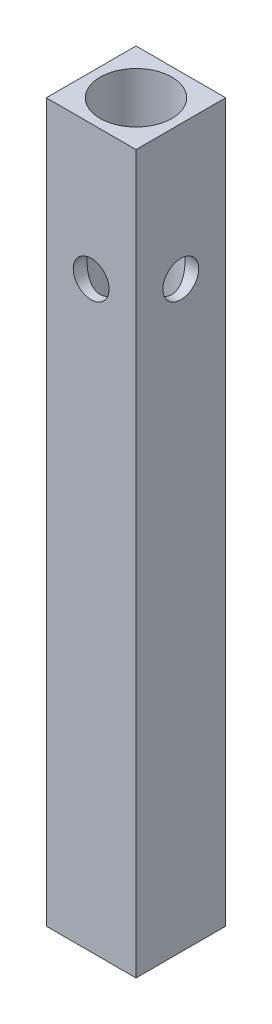
from build123d import *

# Parameters (mm, degrees)
SKETCH_1_W          = 10
SKETCH_1_H          = 10
EXTRUDE_1_DEPTH     = 80
SKETCH_4_R          = 4
CUT_EXTRUDE_3_DEPTH = 75
SKETCH_5_R          = 2
CUT_EXTRUDE_4_DEPTH = 11
SKETCH_6_R          = 2
CUT_EXTRUDE_5_DEPTH = 10


with BuildPart() as part:
    # 草图1 → 凸台-拉伸1 (new body)
    with BuildSketch(Plane(origin=(0, 0, 0), x_dir=(1, 0, 0), z_dir=(0, 1, 0))):
        Rectangle(SKETCH_1_W, SKETCH_1_H)
    extrude(amount=EXTRUDE_1_DEPTH)

    # 草图4 → 切除-拉伸3 (cut)
    with BuildSketch(Plane(origin=(0, 80, 0), x_dir=(1, 0, 0), z_dir=(0, 1, 0))):
        Circle(SKETCH_4_R)
    extrude(amount=-CUT_EXTRUDE_3_DEPTH, mode=Mode.SUBTRACT)

    # 草图5 → 切除-拉伸4 (cut, through all)
    with BuildSketch(Plane(origin=(5, 0, 0), x_dir=(0, 0, -1), z_dir=(1, 0, 0))):
        with Locations((0, 65)):
            Circle(SKETCH_5_R)
    extrude(amount=-CUT_EXTRUDE_4_DEPTH, mode=Mode.SUBTRACT)

    # 草图6 → 切除-拉伸5 (cut)
    with BuildSketch(Plane(origin=(0, 0, -5), x_dir=(-1, 0, 0), z_dir=(0, 0, -1))):
        with Locations((0, 65)):
            Circle(SKETCH_6_R)
    extrude(amount=-CUT_EXTRUDE_5_DEPTH, mode=Mode.SUBTRACT)


solid = part.part
